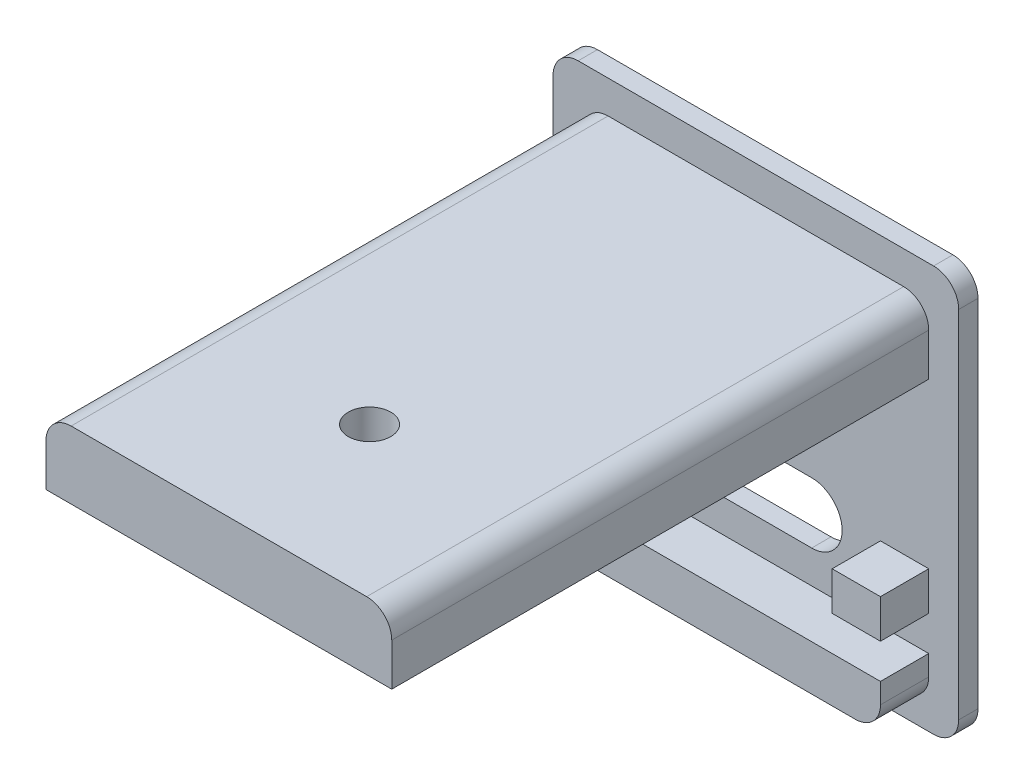
from build123d import *

# Parameters (mm, degrees)
EXTRUDE_1_DEPTH     = 1
SKETCH_3_W          = 2.5
SKETCH_3_H          = 2
EXTRUDE_2_DEPTH     = 2.5
CUT_EXTRUDE_1_DEPTH = 2
EXTRUDE_3_DEPTH     = 27.8
SKETCH_5_R          = 1.1
CUT_EXTRUDE_2_DEPTH = 20.3
CUT_EXTRUDE_3_DEPTH = 1.6


with BuildPart() as part:
    # 草图1 → 凸台-拉伸1 (new body)
    with BuildSketch(Plane.XY):
        with BuildLine():
            Line((-9.2, -10.5), (9.2, -10.5))
            ThreePointArc((9.2, -10.5), (10.119238816, -10.119238816), (10.5, -9.2))
            Line((10.5, -9.2), (10.5, 9.2))
            ThreePointArc((10.5, 9.2), (10.119238816, 10.119238816), (9.2, 10.5))
            Line((9.2, 10.5), (-9.2, 10.5))
            ThreePointArc((-9.2, 10.5), (-10.119238816, 10.119238816), (-10.5, 9.2))
            Line((-10.5, 9.2), (-10.5, -9.2))
            ThreePointArc((-10.5, -9.2), (-10.119238816, -10.119238816), (-9.2, -10.5))
        make_face()
    extrude(amount=EXTRUDE_1_DEPTH)

    # 草图3 → 凸台-拉伸2 (add)
    with BuildSketch(Plane.XY.offset(1)):
        with Locations((7.7, -4.2)):
            Rectangle(SKETCH_3_W, SKETCH_3_H)
        with Locations((-7.7, -4.2)):
            Rectangle(SKETCH_3_W, SKETCH_3_H)
        with BuildLine():
            Line((-8.95, -7), (8.95, -7))
            Line((8.95, -7), (8.95, -8.05))
            ThreePointArc((8.95, -8.05), (8.569238816, -8.969238816), (7.65, -9.35))
            Line((7.65, -9.35), (-7.65, -9.35))
            ThreePointArc((-7.65, -9.35), (-8.569238816, -8.969238816), (-8.95, -8.05))
            Line((-8.95, -8.05), (-8.95, -7))
        make_face()
    extrude(amount=EXTRUDE_2_DEPTH)

    # 草图2 → 切除-拉伸1 (cut, through all)
    with BuildSketch(Plane.XY.offset(1)):
        with BuildLine():
            Line((-2.89, -2.15), (2.89, -2.15))
            ThreePointArc((2.89, -2.15), (4.465, -3.725), (2.89, -5.3))
            Line((2.89, -5.3), (-2.89, -5.3))
            ThreePointArc((-2.89, -5.3), (-4.465, -3.725), (-2.89, -2.15))
        make_face()
    extrude(amount=-CUT_EXTRUDE_1_DEPTH, mode=Mode.SUBTRACT)

    # 草图4 → 凸台-拉伸3 (add)
    with BuildSketch(Plane.XY.offset(1)):
        with BuildLine():
            Line((-7.65, 8.8), (7.65, 8.8))
            ThreePointArc((7.65, 8.8), (8.569238816, 8.419238816), (8.95, 7.5))
            Line((8.95, 7.5), (8.95, 5.3))
            Line((8.95, 5.3), (-8.95, 5.3))
            Line((-8.95, 5.3), (-8.95, 7.5))
            ThreePointArc((-8.95, 7.5), (-8.569238816, 8.419238816), (-7.65, 8.8))
        make_face()
    extrude(amount=EXTRUDE_3_DEPTH)

    # 草图5 → 切除-拉伸2 (cut, through all)
    with BuildSketch(Plane(origin=(0, 8.8, 0), x_dir=(1, 0, 0), z_dir=(0, 1, 0))):
        with Locations((0, -21)):
            Circle(SKETCH_5_R)
    extrude(amount=-CUT_EXTRUDE_2_DEPTH, mode=Mode.SUBTRACT)

    # 草图6 → 切除-拉伸3 (cut)
    with BuildSketch(Plane.XZ.offset(-5.3)):
        Polygon((1.125833025, 22.95), (-1.125833025, 22.95), (-2.25166605, 21), (-1.125833025, 19.05), (1.125833025, 19.05), (2.25166605, 21), align=None)
    extrude(amount=-CUT_EXTRUDE_3_DEPTH, mode=Mode.SUBTRACT)


solid = part.part
